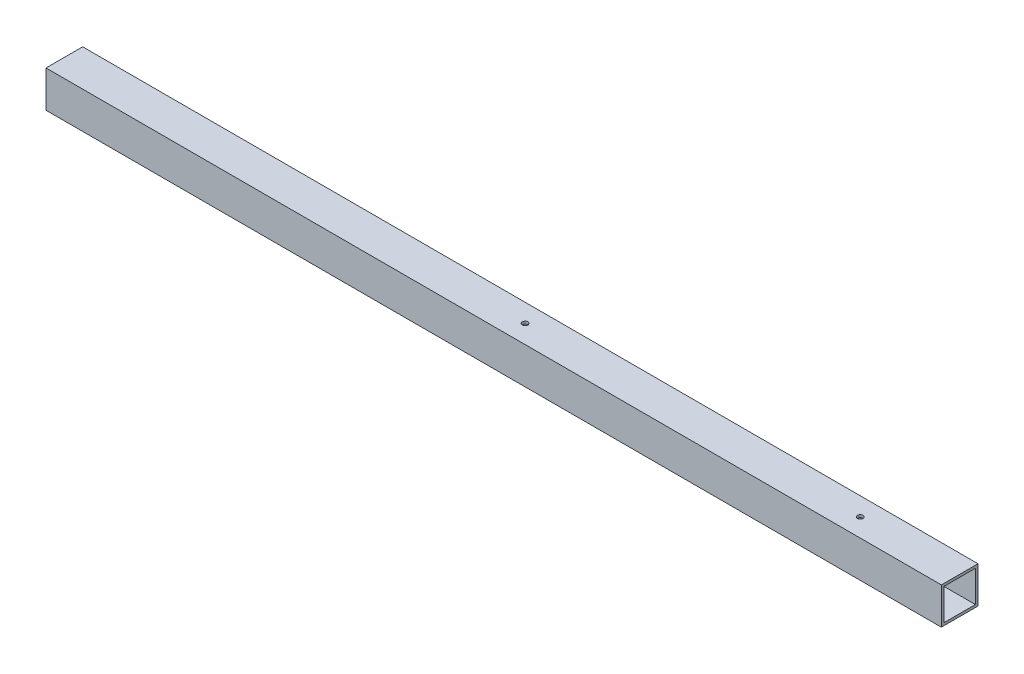
from build123d import *

# Parameters (mm, degrees)
SKETCH1_W                = 1085.85
SKETCH1_H                = 44.45
BOSS_EXTRUDE1_DEPTH      = 44.45
SHELL1_T                 = -3.175
H_0_266_DIAMETER_HOLE1_D = 6.7564


with BuildPart() as part:
    # Sketch1 → Boss-Extrude1 (new body)
    with BuildSketch(Plane.XY):
        with Locations((542.925, 22.225)):
            Rectangle(SKETCH1_W, SKETCH1_H)
    extrude(amount=BOSS_EXTRUDE1_DEPTH)

    # Shell1
    shell1_openings = [part.faces().sort_by_distance(p)[0] for p in [
        (1085.85, 22.225, 22.225),
        (0, 22.225, 22.225),
    ]]
    offset(amount=SHELL1_T, openings=shell1_openings, kind=Kind.INTERSECTION)

    # H (0.266) Diameter Hole1 (through all)
    with Locations(Plane(origin=(0, 44.45, 0), x_dir=(1, 0, 0), z_dir=(0, 1, 0))):
        with Locations((965.2, -22.225), (558.8, -22.225)):
            Hole(H_0_266_DIAMETER_HOLE1_D / 2)


solid = part.part
